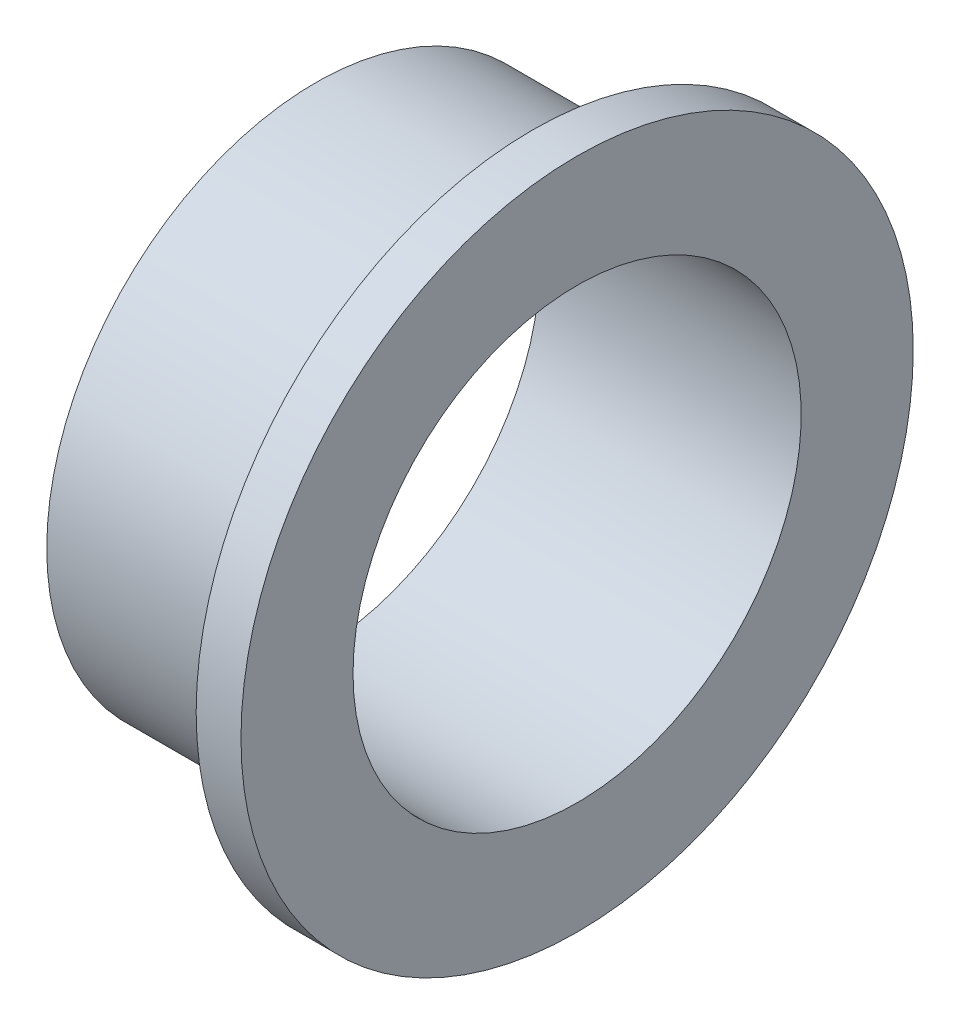
from build123d import *


with BuildPart() as part:
    # Sketch1 → Revolve1 (revolve)
    with BuildSketch(Plane.XY):
        Polygon((-35, 30), (0, 30), (0, 45), (-6, 45), (-6, 36), (-35, 36), align=None)
    revolve(axis=Axis((-57.123287671, 0, 0), (1, 0, 0)))


solid = part.part
